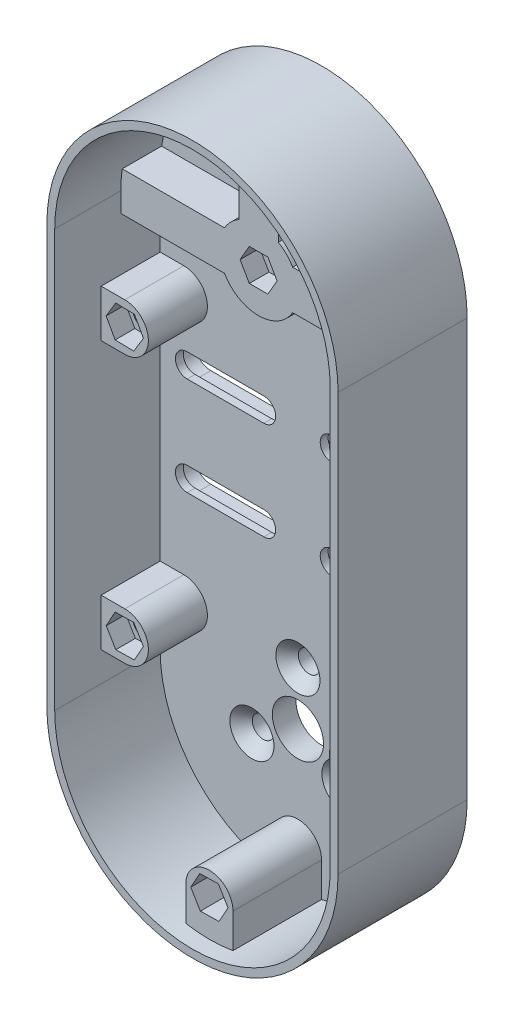
from build123d import *

# Parameters (mm, degrees)
SALIENTE_EXTRUIR1_DEPTH                              = 4
CROQUIS2_R                                           = 2.75
SALIENTE_EXTRUIR2_DEPTH                              = 10
SALIENTE_EXTRUIR3_DEPTH                              = 30.8
CROQUIS4_R                                           = 2.75
CORTAR_EXTRUIR1_DEPTH                                = 4
REFRENTADO_PARA_TORNILLO_TAP_N_CON_CABEZ_D           = 5.5
REFRENTADO_PARA_TORNILLO_TAP_N_CON_CABEZ_CSINK_D     = 11.2
REFRENTADO_PARA_TORNILLO_TAP_N_CON_CABEZ_CSINK_ANGLE = 90
CORTAR_EXTRUIR2_DEPTH                                = 5
CORTAR_EXTRUIR3_DEPTH                                = 5
CROQUIS16_W                                          = 74
CROQUIS16_H                                          = 4
CORTAR_EXTRUIR5_DEPTH                                = 35
SALIENTE_EXTRUIR4_DEPTH                              = 4
SALIENTE_EXTRUIR5_DEPTH                              = 4
SALIENTE_EXTRUIR6_DEPTH                              = 26.8
REFRENTADO_PARA_TORNILLO_TAP_N_CON_C_2_A_COUNT       = 2
REFRENTADO_PARA_TORNILLO_TAP_N_CON_C_2_A_PITCH       = 23.382685902
REFRENTADO_PARA_TORNILLO_TAP_N_CON_C_3_COUNT         = 2
REFRENTADO_PARA_TORNILLO_TAP_N_CON_C_3_PITCH         = 23.382685902
CROQUIS19_R                                          = 6.5
CORTAR_EXTRUIR6_DEPTH                                = 10
CORTAR_EXTRUIR7_DEPTH                                = 10
SALIENTE_EXTRUIR7_DEPTH                              = 22.5
SALIENTE_EXTRUIR8_DEPTH                              = 15
CROQUIS28_R                                          = 3
CORTAR_EXTRUIR9_DEPTH                                = 15
SALIENTE_EXTRUIR9_DEPTH                              = 15
SALIENTE_EXTRUIR10_DEPTH                             = 10
CROQUIS31_R                                          = 3
CORTAR_EXTRUIR10_DEPTH                               = 10
CROQUIS35_R                                          = 2.75
CROQUIS35_R_2                                        = 5.6
CROQUIS35_R_3                                        = 6.5
SALIENTE_EXTRUIR11_DEPTH                             = 2
CORTAR_EXTRUIR12_DEPTH                               = 4


with BuildPart() as part:
    # Croquis1 → Saliente-Extruir1 (new body)
    with BuildSketch(Plane.XY):
        with BuildLine():
            Line((-35, 0), (35, 0))
            Line((35, 0), (35, 110))
            ThreePointArc((35, 110), (0, 145), (-35, 110))
            Line((-35, 110), (-35, 0))
        make_face()
    extrude(amount=SALIENTE_EXTRUIR1_DEPTH)

    # Croquis2 → Saliente-Extruir2 (add)
    with BuildSketch(Plane.XY.offset(4)):
        with BuildLine():
            Line((-35, 105), (-8.660254038, 105))
            ThreePointArc((-8.660254038, 105), (0, 100), (8.660254038, 105))
            Line((8.660254038, 105), (35, 105))
            Line((35, 105), (35, 110))
            ThreePointArc((35, 110), (34.91013868, 112.506435188), (34.641016151, 115))
            Line((34.641016151, 115), (8.660254038, 115))
            ThreePointArc((8.660254038, 115), (7.071067812, 117.071067812), (5, 118.660254038))
            Line((5, 118.660254038), (5, 144.641016151))
            ThreePointArc((5, 144.641016151), (0, 145), (-5, 144.641016151))
            Line((-5, 144.641016151), (-5, 118.660254038))
            ThreePointArc((-5, 118.660254038), (-7.071067812, 117.071067812), (-8.660254038, 115))
            Line((-8.660254038, 115), (-34.641016151, 115))
            ThreePointArc((-34.641016151, 115), (-34.91013868, 112.506435188), (-35, 110))
            Line((-35, 110), (-35, 105))
        make_face()
        with Locations((0, 110)):
            Circle(CROQUIS2_R, mode=Mode.SUBTRACT)
    extrude(amount=SALIENTE_EXTRUIR2_DEPTH)

    # Croquis3 → Saliente-Extruir3 (add)
    with BuildSketch(Plane(origin=(0, 0, 0), x_dir=(-1, 0, 0), z_dir=(0, 0, -1))):
        with BuildLine():
            Line((-35, 0), (-35, 110))
            ThreePointArc((-35, 110), (0, 145), (35, 110))
            Line((35, 110), (35, 0))
            Line((35, 0), (37, 0))
            Line((37, 0), (37, 110))
            ThreePointArc((37, 110), (0, 147), (-37, 110))
            Line((-37, 110), (-37, 0))
            Line((-37, 0), (-35, 0))
        make_face()
    extrude(amount=-SALIENTE_EXTRUIR3_DEPTH)

    # Croquis4 → Cortar-Extruir1 (cut)
    with BuildSketch(Plane.XY.offset(4)):
        with Locations((0, 110)):
            Circle(CROQUIS4_R)
    extrude(amount=-CORTAR_EXTRUIR1_DEPTH, mode=Mode.SUBTRACT)

    # Refrentado para tornillo tap_n con cabez (through all)
    with Locations(Plane(origin=(0, 110, 0), x_dir=(-1, 0, 0), z_dir=(0, 0, -1))):
        with Locations((0, 0)):
            CounterSinkHole(REFRENTADO_PARA_TORNILLO_TAP_N_CON_CABEZ_D / 2, REFRENTADO_PARA_TORNILLO_TAP_N_CON_CABEZ_CSINK_D / 2, counter_sink_angle=REFRENTADO_PARA_TORNILLO_TAP_N_CON_CABEZ_CSINK_ANGLE)

    # Croquis7 → Cortar-Extruir2 (cut)
    with BuildSketch(Plane(origin=(0, 0, 0), x_dir=(-1, 0, 0), z_dir=(0, 0, -1))):
        Polygon((2.189291013, 105.834926388), (4.701705063, 109.813444827), (2.512414051, 113.978518439), (-2.189291013, 114.165073612), (-4.701705063, 110.186555173), (-2.512414051, 106.021481561), align=None)
    extrude(amount=-CORTAR_EXTRUIR2_DEPTH, mode=Mode.SUBTRACT)

    # Croquis8 → Cortar-Extruir3 (cut)
    with BuildSketch(Plane.XY.offset(14)):
        Polygon((4.705404694, 110), (2.352702347, 114.075), (-2.352702347, 114.075), (-4.705404694, 110), (-2.352702347, 105.925), (2.352702347, 105.925), align=None)
    extrude(amount=-CORTAR_EXTRUIR3_DEPTH, mode=Mode.SUBTRACT)

    # Croquis16 → Cortar-Extruir5 (cut, symmetric)
    with BuildSketch(Plane.XY.offset(4)):
        with Locations((0, 2)):
            Rectangle(CROQUIS16_W, CROQUIS16_H)
    extrude(amount=CORTAR_EXTRUIR5_DEPTH, both=True, mode=Mode.SUBTRACT)

    # Croquis15 → Saliente-Extruir4 (add)
    with BuildSketch(Plane.XY.offset(4)):
        with BuildLine():
            Line((35, 4), (0, 4))
            Line((0, 4), (-35, 4))
            ThreePointArc((-35, 4), (0, -31), (35, 4))
        make_face()
    extrude(amount=-SALIENTE_EXTRUIR4_DEPTH)

    # Croquis17 → Saliente-Extruir5 (add)
    with BuildSketch(Plane.XY.offset(4)):
        with BuildLine():
            Line((-37, 4), (-35, 4))
            ThreePointArc((-35, 4), (0, -31), (35, 4))
            Line((35, 4), (37, 4))
            ThreePointArc((37, 4), (0, -33), (-37, 4))
        make_face()
    extrude(amount=-SALIENTE_EXTRUIR5_DEPTH)

    # Croquis18 → Saliente-Extruir6 (add)
    with BuildSketch(Plane.XY.offset(4)):
        with BuildLine():
            Line((-37, 4), (-35, 4))
            ThreePointArc((-35, 4), (0, -31), (35, 4))
            Line((35, 4), (37, 4))
            ThreePointArc((37, 4), (0, -33), (-37, 4))
        make_face()
    extrude(amount=SALIENTE_EXTRUIR6_DEPTH)

    # Croquis21 → Refrentado para tornillo tap_n con c 2 (revolve, cut)
    with BuildSketch(Plane(origin=(0, 17.5, 4), x_dir=(0, -1, 0), z_dir=(1, 0, 0))):
        Polygon((0, 0), (0, 4), (2.75, 4), (2.75, 2.85), (5.6, 0), align=None)
    refrentado_para_tornillo_tap_n_con_c_2 = revolve(axis=Axis((0, 17.5, 10.35), (0, 0, -1)), mode=Mode.SUBTRACT)

    # Refrentado para tornillo tap_n con c 2 a: Refrentado para tornillo tap_n con c 2 ×2
    with Locations(*[Vector(-0.4999999999998842, -0.8660254037845055, 0) * (i * REFRENTADO_PARA_TORNILLO_TAP_N_CON_C_2_A_PITCH) for i in range(1, REFRENTADO_PARA_TORNILLO_TAP_N_CON_C_2_A_COUNT)]):
        add(refrentado_para_tornillo_tap_n_con_c_2, mode=Mode.SUBTRACT)

    # Refrentado para tornillo tap_n con c 3: Refrentado para tornillo tap_n con c 2 ×2
    with Locations(*[Vector(0.500000000000118, -0.8660254037843707, 0) * (i * REFRENTADO_PARA_TORNILLO_TAP_N_CON_C_3_PITCH) for i in range(1, REFRENTADO_PARA_TORNILLO_TAP_N_CON_C_3_COUNT)]):
        add(refrentado_para_tornillo_tap_n_con_c_2, mode=Mode.SUBTRACT)

    # Croquis19 → Cortar-Extruir6 (cut)
    with BuildSketch(Plane.XY.offset(4)):
        with Locations((0, 4)):
            Circle(CROQUIS19_R)
    extrude(amount=-CORTAR_EXTRUIR6_DEPTH, mode=Mode.SUBTRACT)

    # Croquis23 → Cortar-Extruir7 (cut)
    with BuildSketch(Plane.XY.offset(4)):
        with BuildLine():
            Line((-28.137558794, 73), (-8.660254038, 73))
            ThreePointArc((-8.660254038, 73), (-5.660254038, 70), (-8.660254038, 67))
            Line((-8.660254038, 67), (-28.137558794, 67))
            ThreePointArc((-28.137558794, 67), (-31.137558794, 70), (-28.137558794, 73))
        make_face()
        with BuildLine():
            Line((28.137558794, 73), (8.660254038, 73))
            ThreePointArc((8.660254038, 73), (5.660254038, 70), (8.660254038, 67))
            Line((8.660254038, 67), (28.137558794, 67))
            ThreePointArc((28.137558794, 67), (31.137558794, 70), (28.137558794, 73))
        make_face()
        with BuildLine():
            Line((28.137558794, 42), (8.660254038, 42))
            ThreePointArc((8.660254038, 42), (5.660254038, 45), (8.660254038, 48))
            Line((8.660254038, 48), (28.137558794, 48))
            ThreePointArc((28.137558794, 48), (31.137558794, 45), (28.137558794, 42))
        make_face()
        with BuildLine():
            Line((-28.137558794, 42), (-8.660254038, 42))
            ThreePointArc((-8.660254038, 42), (-5.660254038, 45), (-8.660254038, 48))
            Line((-8.660254038, 48), (-28.137558794, 48))
            ThreePointArc((-28.137558794, 48), (-31.137558794, 45), (-28.137558794, 42))
        make_face()
    extrude(amount=-CORTAR_EXTRUIR7_DEPTH, mode=Mode.SUBTRACT)

    # Croquis26 → Saliente-Extruir7 (add)
    with BuildSketch(Plane.XY.offset(4)):
        with BuildLine():
            Line((-6, -30.481879299), (-6, -21.783477858))
            ThreePointArc((-6, -21.783477858), (0, -15.783477858), (6, -21.783477858))
            Line((6, -21.783477858), (6, -30.481879299))
            ThreePointArc((6, -30.481879299), (0, -31), (-6, -30.481879299))
        make_face()
        Polygon((2.443844369, -25.838222984), (4.733434469, -21.694419114), (2.2895901, -17.639673989), (-2.443844369, -17.728732733), (-4.733434469, -21.872536602), (-2.2895901, -25.927281728), align=None, mode=Mode.SUBTRACT)
    extrude(amount=SALIENTE_EXTRUIR7_DEPTH)

    # Croquis27 → Saliente-Extruir8 (add)
    with BuildSketch(Plane.XY.offset(4)):
        Polygon((-4.733434469, -21.872536602), (-2.2895901, -25.927281728), (2.443844369, -25.838222984), (4.733434469, -21.694419114), (2.2895901, -17.639673989), (-2.443844369, -17.728732733), align=None)
        Polygon((-1.17271688, -23.905913986), (1.251725165, -23.860298532), (2.424442045, -21.737862404), (1.17271688, -19.66104173), (-1.251725165, -19.706657184), (-2.424442045, -21.829093313), align=None, mode=Mode.SUBTRACT)
    extrude(amount=SALIENTE_EXTRUIR8_DEPTH)

    # Croquis28 → Cortar-Extruir9 (cut)
    with BuildSketch(Plane.XY.offset(19)):
        with Locations((0, -21.783477858)):
            Circle(CROQUIS28_R)
    extrude(amount=-CORTAR_EXTRUIR9_DEPTH, mode=Mode.SUBTRACT)

    # Croquis29 → Saliente-Extruir9 (add)
    with BuildSketch(Plane.XY.offset(4)):
        with BuildLine():
            Line((-35, 23.5), (-29, 23.5))
            ThreePointArc((-29, 23.5), (-23, 17.5), (-29, 11.5))
            Line((-29, 11.5), (-35, 11.5))
            Line((-35, 11.5), (-35, 23.5))
        make_face()
        Polygon((-31.286531855, 13.354507821), (-26.553164389, 13.447059237), (-24.266632534, 17.592551416), (-26.713468145, 21.645492179), (-31.446835611, 21.552940763), (-33.733367466, 17.407448584), align=None, mode=Mode.SUBTRACT)
        with BuildLine():
            Line((35, 23.5), (35, 11.5))
            Line((35, 11.5), (29, 11.5))
            ThreePointArc((29, 11.5), (23, 17.5), (29, 23.5))
            Line((29, 23.5), (35, 23.5))
        make_face()
        Polygon((33.733367466, 17.407448584), (31.286531855, 13.354507821), (26.553164389, 13.447059237), (24.266632534, 17.592551416), (26.713468145, 21.645492179), (31.446835611, 21.552940763), align=None, mode=Mode.SUBTRACT)
        with BuildLine():
            Line((35, 79.5), (35, 91.5))
            Line((35, 91.5), (29, 91.5))
            ThreePointArc((29, 91.5), (23, 85.5), (29, 79.5))
            Line((29, 79.5), (35, 79.5))
        make_face()
        Polygon((31.286531855, 89.645492179), (26.553164389, 89.552940763), (24.266632534, 85.407448584), (26.713468145, 81.354507821), (31.446835611, 81.447059237), (33.733367466, 85.592551416), align=None, mode=Mode.SUBTRACT)
        with BuildLine():
            Line((-35, 79.5), (-35, 91.5))
            Line((-35, 91.5), (-29, 91.5))
            ThreePointArc((-29, 91.5), (-23, 85.5), (-29, 79.5))
            Line((-29, 79.5), (-35, 79.5))
        make_face()
        Polygon((-33.733367466, 85.592551416), (-31.286531855, 89.645492179), (-26.553164389, 89.552940763), (-24.266632534, 85.407448584), (-26.713468145, 81.354507821), (-31.446835611, 81.447059237), align=None, mode=Mode.SUBTRACT)
    extrude(amount=SALIENTE_EXTRUIR9_DEPTH)

    # Croquis30 → Saliente-Extruir10 (add)
    with BuildSketch(Plane.XY.offset(4)):
        Polygon((-33.733367466, 17.407448584), (-31.286531855, 13.354507821), (-26.553164389, 13.447059237), (-24.266632534, 17.592551416), (-26.713468145, 21.645492179), (-31.446835611, 21.552940763), align=None)
        Polygon((-31.424407727, 17.452595616), (-30.171150462, 15.376699128), (-27.746742736, 15.424103512), (-26.575592273, 17.547404384), (-27.828849538, 19.623300872), (-30.253257264, 19.575896488), align=None, mode=Mode.SUBTRACT)
        Polygon((31.286531855, 13.354507821), (26.553164389, 13.447059237), (24.266632534, 17.592551416), (26.713468145, 21.645492179), (31.446835611, 21.552940763), (33.733367466, 17.407448584), align=None)
        Polygon((27.746742736, 15.424103512), (26.575592273, 17.547404384), (27.828849538, 19.623300872), (30.253257264, 19.575896488), (31.424407727, 17.452595616), (30.171150462, 15.376699128), align=None, mode=Mode.SUBTRACT)
        Polygon((-26.553164389, 89.552940763), (-24.266632534, 85.407448584), (-26.713468145, 81.354507821), (-31.446835611, 81.447059237), (-33.733367466, 85.592551416), (-31.286531855, 89.645492179), align=None)
        Polygon((-30.253257264, 83.424103512), (-31.424407727, 85.547404384), (-30.171150462, 87.623300872), (-27.746742736, 87.575896488), (-26.575592273, 85.452595616), (-27.828849538, 83.376699128), align=None, mode=Mode.SUBTRACT)
        Polygon((31.286531855, 89.645492179), (26.553164389, 89.552940763), (24.266632534, 85.407448584), (26.713468145, 81.354507821), (31.446835611, 81.447059237), (33.733367466, 85.592551416), align=None)
        Polygon((31.424407727, 85.547404384), (30.171150462, 87.623300872), (27.746742736, 87.575896488), (26.575592273, 85.452595616), (27.828849538, 83.376699128), (30.253257264, 83.424103512), align=None, mode=Mode.SUBTRACT)
    extrude(amount=SALIENTE_EXTRUIR10_DEPTH)

    # Croquis31 → Cortar-Extruir10 (cut)
    with BuildSketch(Plane.XY.offset(14)):
        with Locations((-29, 17.5)):
            Circle(CROQUIS31_R)
        with Locations(Location((29, 17.5, 0), (0, 0, 180))):
            Circle(CROQUIS31_R)
        with Locations((-29, 85.5)):
            Circle(CROQUIS31_R)
        with Locations((29, 85.5)):
            Circle(CROQUIS31_R)
    extrude(amount=-CORTAR_EXTRUIR10_DEPTH, mode=Mode.SUBTRACT)

    # Croquis35 → Saliente-Extruir11 (add)
    with BuildSketch(Plane(origin=(0, 0, 0), x_dir=(-1, 0, 0), z_dir=(0, 0, -1))):
        with BuildLine():
            Line((-37, 110), (-37, 4))
            ThreePointArc((-37, 4), (0, -33), (37, 4))
            Line((37, 4), (37, 110))
            ThreePointArc((37, 110), (0, 147), (-37, 110))
        make_face()
        with Locations(Location((0, 17.5, 0), (0, 0, 180))):
            Circle(CROQUIS35_R, mode=Mode.SUBTRACT)
        with Locations(Location((-11.691342951, -2.75, 0), (0, 0, 180))):
            Circle(CROQUIS35_R, mode=Mode.SUBTRACT)
        with Locations((0, 110)):
            Circle(CROQUIS35_R_2, mode=Mode.SUBTRACT)
        with Locations(Location((11.691342951, -2.75, 0), (0, 0, 180))):
            Circle(CROQUIS35_R, mode=Mode.SUBTRACT)
        with Locations(Location((0, 4, 0), (0, 0, 180))):
            Circle(CROQUIS35_R_3, mode=Mode.SUBTRACT)
        with BuildLine():
            ThreePointArc((-8.660254038, 48), (-5.660254038, 45), (-8.660254038, 42))
            Line((-8.660254038, 42), (-28.137558794, 42))
            ThreePointArc((-28.137558794, 42), (-31.137558794, 45), (-28.137558794, 48))
            Line((-28.137558794, 48), (-8.660254038, 48))
        make_face(mode=Mode.SUBTRACT)
        with BuildLine():
            ThreePointArc((8.660254038, 67), (5.660254038, 70), (8.660254038, 73))
            Line((8.660254038, 73), (28.137558794, 73))
            ThreePointArc((28.137558794, 73), (31.137558794, 70), (28.137558794, 67))
            Line((28.137558794, 67), (8.660254038, 67))
        make_face(mode=Mode.SUBTRACT)
        with BuildLine():
            ThreePointArc((-8.660254038, 73), (-5.660254038, 70), (-8.660254038, 67))
            Line((-8.660254038, 67), (-28.137558794, 67))
            ThreePointArc((-28.137558794, 67), (-31.137558794, 70), (-28.137558794, 73))
            Line((-28.137558794, 73), (-8.660254038, 73))
        make_face(mode=Mode.SUBTRACT)
        with BuildLine():
            ThreePointArc((8.660254038, 42), (5.660254038, 45), (8.660254038, 48))
            Line((8.660254038, 48), (28.137558794, 48))
            ThreePointArc((28.137558794, 48), (31.137558794, 45), (28.137558794, 42))
            Line((28.137558794, 42), (8.660254038, 42))
        make_face(mode=Mode.SUBTRACT)
    extrude(amount=SALIENTE_EXTRUIR11_DEPTH)

    # Croquis36 → Cortar-Extruir12 (cut)
    with BuildSketch(Plane(origin=(0, 0, -2), x_dir=(-1, 0, 0), z_dir=(0, 0, -1))):
        with BuildLine():
            Line((-28.137558794, 74.15), (-8.660254038, 74.15))
            ThreePointArc((-8.660254038, 74.15), (-4.510254038, 70), (-8.660254038, 65.85))
            Line((-8.660254038, 65.85), (-28.137558794, 65.85))
            ThreePointArc((-28.137558794, 65.85), (-32.287558794, 70), (-28.137558794, 74.15))
        make_face()
        with BuildLine():
            Line((28.137558794, 74.15), (8.660254038, 74.15))
            ThreePointArc((8.660254038, 74.15), (4.510254038, 70), (8.660254038, 65.85))
            Line((8.660254038, 65.85), (28.137558794, 65.85))
            ThreePointArc((28.137558794, 65.85), (32.287558794, 70), (28.137558794, 74.15))
        make_face()
        with BuildLine():
            Line((-28.137558794, 40.85), (-8.660254038, 40.85))
            ThreePointArc((-8.660254038, 40.85), (-4.510254038, 45), (-8.660254038, 49.15))
            Line((-8.660254038, 49.15), (-28.137558794, 49.15))
            ThreePointArc((-28.137558794, 49.15), (-32.287558794, 45), (-28.137558794, 40.85))
        make_face()
        with BuildLine():
            Line((28.137558794, 40.85), (8.660254038, 40.85))
            ThreePointArc((8.660254038, 40.85), (4.510254038, 45), (8.660254038, 49.15))
            Line((8.660254038, 49.15), (28.137558794, 49.15))
            ThreePointArc((28.137558794, 49.15), (32.287558794, 45), (28.137558794, 40.85))
        make_face()
    extrude(amount=-CORTAR_EXTRUIR12_DEPTH, mode=Mode.SUBTRACT)


solid = part.part
